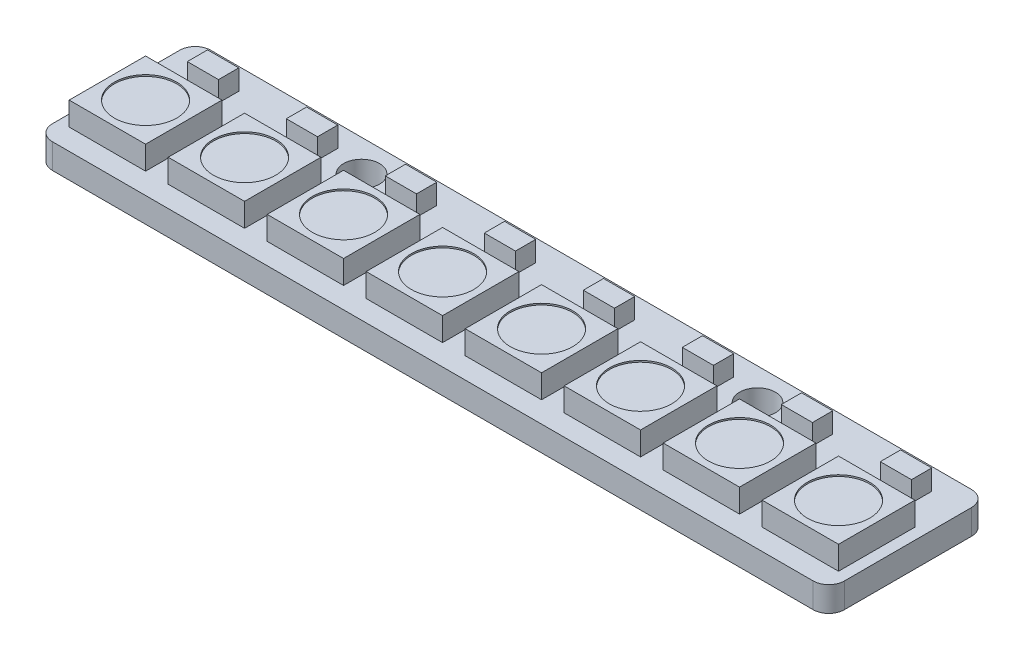
from build123d import *

# Parameters (mm, degrees)
SKETCH1_W         = 50.8
SKETCH1_H         = 10.16
SKETCH1_R         = 1.15
PCB_DEPTH         = 1.6
SKETCH2_W         = 4.9
SKETCH2_H         = 4.9
LEDS_DEPTH        = 1.5
SKETCH3_W         = 2
SKETCH3_H         = 1.3
CAPS_DEPTH        = 1.3
SKETCH4_R         = 2
LED_WINDOWS_DEPTH = 0.1
FILED_FILLETS_R   = 1


with BuildPart() as part:
    # Sketch1 → PCB (new body)
    with BuildSketch(Plane(origin=(0, 0, 0), x_dir=(1, 0, 0), z_dir=(0, 1, 0))):
        Rectangle(SKETCH1_W, SKETCH1_H)
        with Locations((-12.7, 3.048)):
            Circle(SKETCH1_R, mode=Mode.SUBTRACT)
        with Locations((12.7, 3.048)):
            Circle(SKETCH1_R, mode=Mode.SUBTRACT)
    extrude(amount=PCB_DEPTH)

    # Sketch2 → LEDs (add)
    with BuildSketch(Plane(origin=(0, 1.6, 0), x_dir=(1, 0, 0), z_dir=(0, 1, 0))):
        with Locations((3.175, -1.28)):
            Rectangle(SKETCH2_W, SKETCH2_H)
        with Locations((-3.175, -1.28)):
            Rectangle(SKETCH2_W, SKETCH2_H)
        with Locations((9.525, -1.28)):
            Rectangle(SKETCH2_W, SKETCH2_H)
        with Locations((15.875, -1.28)):
            Rectangle(SKETCH2_W, SKETCH2_H)
        with Locations((22.225, -1.28)):
            Rectangle(SKETCH2_W, SKETCH2_H)
        with Locations((-22.225, -1.28)):
            Rectangle(SKETCH2_W, SKETCH2_H)
        with Locations((-15.875, -1.28)):
            Rectangle(SKETCH2_W, SKETCH2_H)
        with Locations((-9.525, -1.28)):
            Rectangle(SKETCH2_W, SKETCH2_H)
    extrude(amount=LEDS_DEPTH)

    # Sketch3 → Caps (add)
    with BuildSketch(Plane(origin=(0, 1.6, 0), x_dir=(1, 0, 0), z_dir=(0, 1, 0))):
        with Locations((-15.875, 3.048)):
            Rectangle(SKETCH3_W, SKETCH3_H)
        with Locations((-22.225, 3.048)):
            Rectangle(SKETCH3_W, SKETCH3_H)
        with Locations((-9.525, 3.048)):
            Rectangle(SKETCH3_W, SKETCH3_H)
        with Locations((-3.175, 3.048)):
            Rectangle(SKETCH3_W, SKETCH3_H)
        with Locations((3.175, 3.048)):
            Rectangle(SKETCH3_W, SKETCH3_H)
        with Locations((9.525, 3.048)):
            Rectangle(SKETCH3_W, SKETCH3_H)
        with Locations((15.875, 3.048)):
            Rectangle(SKETCH3_W, SKETCH3_H)
        with Locations((22.225, 3.048)):
            Rectangle(SKETCH3_W, SKETCH3_H)
    extrude(amount=CAPS_DEPTH)

    # Sketch4 → LED windows (cut)
    with BuildSketch(Plane(origin=(0, 3.1, 0), x_dir=(1, 0, 0), z_dir=(0, 1, 0))):
        with Locations((-22.225, -1.28)):
            Circle(SKETCH4_R)
        with Locations((-15.875, -1.28)):
            Circle(SKETCH4_R)
        with Locations((-9.525, -1.28)):
            Circle(SKETCH4_R)
        with Locations((-3.175, -1.28)):
            Circle(SKETCH4_R)
        with Locations((3.175, -1.28)):
            Circle(SKETCH4_R)
        with Locations((9.525, -1.28)):
            Circle(SKETCH4_R)
        with Locations((15.875, -1.28)):
            Circle(SKETCH4_R)
        with Locations((22.225, -1.28)):
            Circle(SKETCH4_R)
    extrude(amount=-LED_WINDOWS_DEPTH, mode=Mode.SUBTRACT)

    # Filed fillets
    filed_fillets_edges = [part.edges().sort_by_distance(p)[0] for p in [
        (25.4, 0.8, 5.08),
        (-25.4, 0.8, 5.08),
        (-25.4, 0.8, -5.08),
        (25.4, 0.8, -5.08),
    ]]
    fillet(filed_fillets_edges, radius=FILED_FILLETS_R)


solid = part.part
